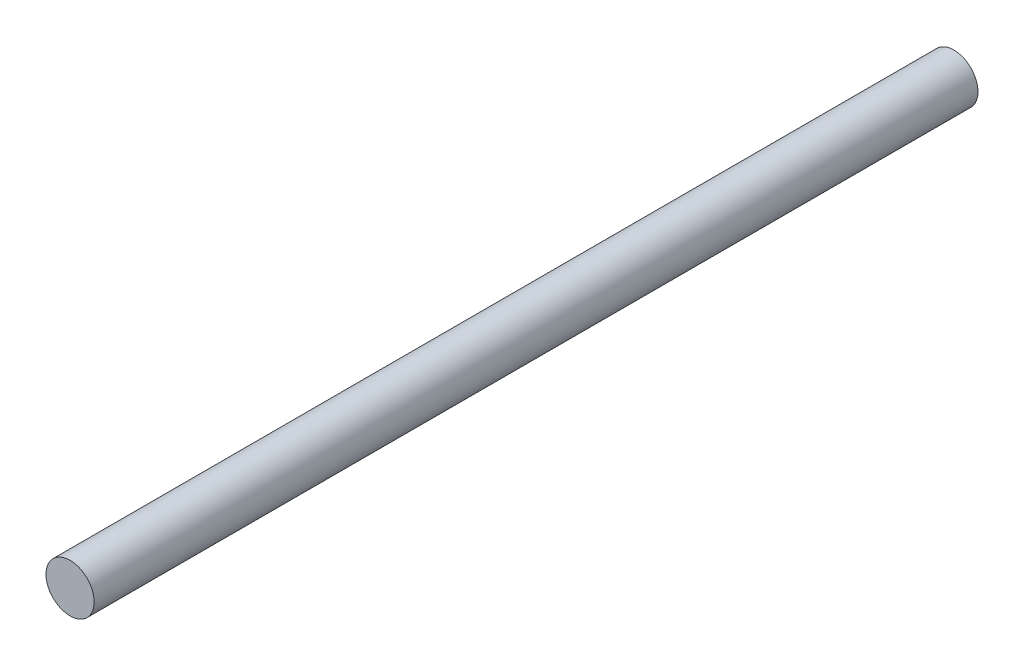
from build123d import *

# Parameters (mm, degrees)
SKETCH1_R           = 3
BOSS_EXTRUDE1_DEPTH = 110


with BuildPart() as part:
    # Sketch1 → Boss-Extrude1 (new body)
    with BuildSketch(Plane.XY):
        Circle(SKETCH1_R)
    extrude(amount=BOSS_EXTRUDE1_DEPTH)


solid = part.part
